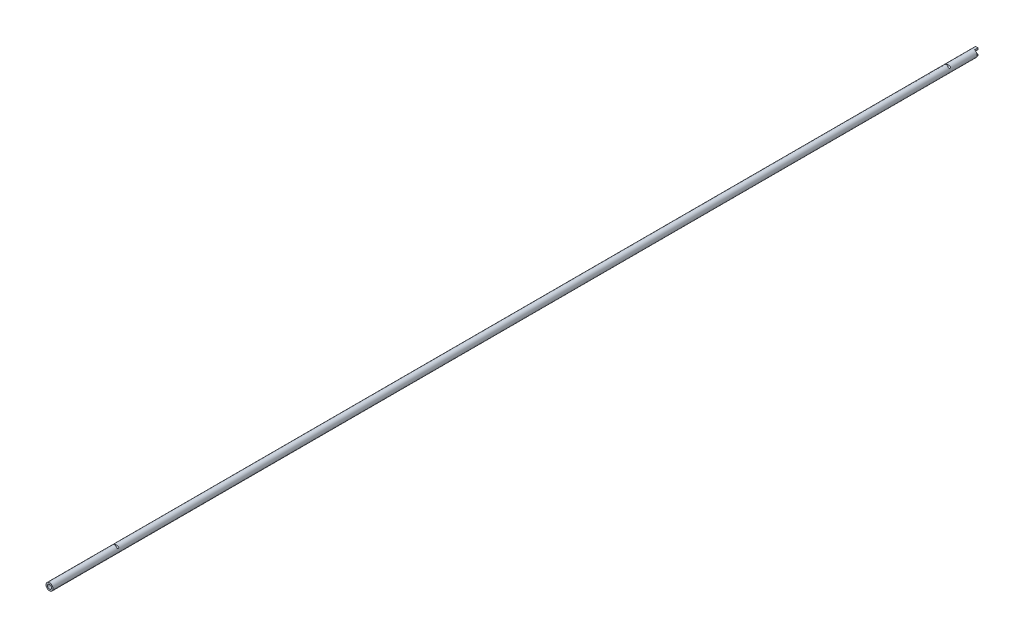
from build123d import *

# Parameters (mm, degrees)
SKETCH1_R           = 1.98
SKETCH1_R_2         = 1.125
EXTRUDE1_DEPTH      = 522
SKETCH2_R           = 0.5
EXTRUDE2_DEPTH      = 2.98
EXTRUDE2_DEPTH_BACK = 2.98
SKETCH3_W           = 2.698417422
SKETCH3_H           = 6
EXTRUDE5_DEPTH      = 2


with BuildPart() as part:
    # Sketch1 → Extrude1 (new body)
    with BuildSketch(Plane.XY):
        Circle(SKETCH1_R)
        Circle(SKETCH1_R_2, mode=Mode.SUBTRACT)
    extrude(amount=EXTRUDE1_DEPTH)

    # Sketch2 → Extrude2 (cut, two sides)
    with BuildSketch(Plane(origin=(0, 0, 0), x_dir=(0, 0, -1), z_dir=(1, 0, 0))) as extrude2_sk:
        with Locations((-485, 1.5)):
            Circle(SKETCH2_R)
        with Locations((-17, 1.5)):
            Circle(SKETCH2_R)
    extrude(amount=EXTRUDE2_DEPTH, mode=Mode.SUBTRACT)
    extrude(extrude2_sk.sketch, amount=-EXTRUDE2_DEPTH_BACK, mode=Mode.SUBTRACT)

    # Sketch3 → Extrude5 (cut)
    with BuildSketch(Plane.XY):
        with Locations((1.849208711, 0)):
            Rectangle(SKETCH3_W, SKETCH3_H)
    extrude(amount=EXTRUDE5_DEPTH, mode=Mode.SUBTRACT)


solid = part.part
